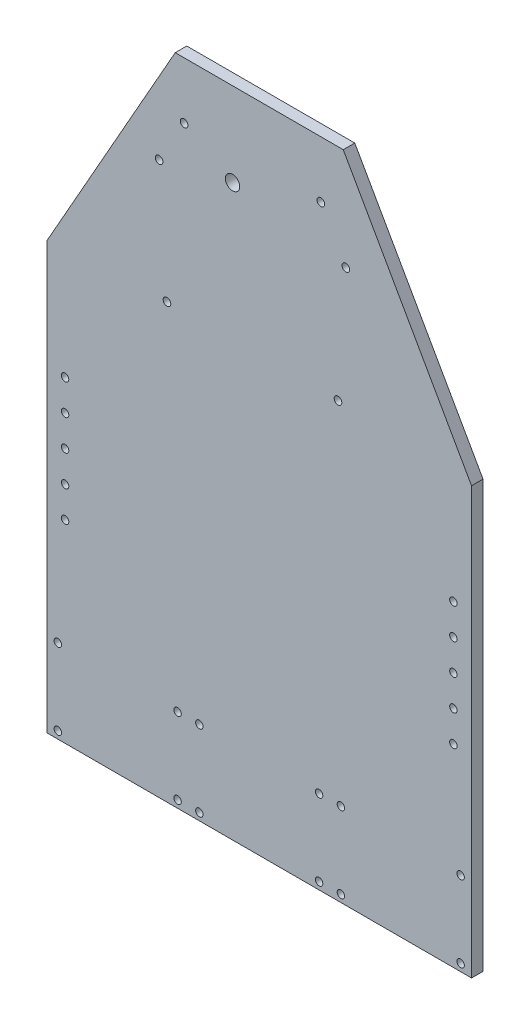
from build123d import *

# Parameters (mm, degrees)
SKETCH1_W           = 234
SKETCH1_H           = 360
BOSS_EXTRUDE1_DEPTH = 6.35
SKETCH2_R           = 2.05
SKETCH2_R_2         = 3.96875
SKETCH2_R_3         = 2.1
CUT_EXTRUDE1_DEPTH  = 10


with BuildPart() as part:
    # Sketch1 → Boss-Extrude1 (new body)
    with BuildSketch(Plane.XY):
        with Locations((3.724430118, 68.459164491)):
            Rectangle(SKETCH1_W, SKETCH1_H)
    extrude(amount=BOSS_EXTRUDE1_DEPTH)

    # Sketch2 → Cut-Extrude1 (cut)
    with BuildSketch(Plane(origin=(0, 0, 0), x_dir=(-1, 0, 0), z_dir=(0, 0, -1))):
        with Locations((107.275569882, -107.540835509)):
            Circle(SKETCH2_R)
        with Locations((107.275569882, -65.540835509)):
            Circle(SKETCH2_R)
        with Locations((41.275569882, -107.540835509)):
            Circle(SKETCH2_R)
        with Locations((41.275569882, -65.540835509)):
            Circle(SKETCH2_R)
        with Locations((29.275569882, -107.540835509)):
            Circle(SKETCH2_R)
        with Locations((29.275569882, -65.540835509)):
            Circle(SKETCH2_R)
        with Locations((-36.724430118, -107.540835509)):
            Circle(SKETCH2_R)
        with Locations((-36.724430118, -65.540835509)):
            Circle(SKETCH2_R)
        with Locations((-48.724430118, -107.540835509)):
            Circle(SKETCH2_R)
        with Locations((-48.724430118, -65.540835509)):
            Circle(SKETCH2_R)
        with Locations((-114.724430118, -107.540835509)):
            Circle(SKETCH2_R)
        with Locations((-114.724430118, -65.540835509)):
            Circle(SKETCH2_R)
        with Locations((10.98704263, 202.255343847)):
            Circle(SKETCH2_R_2)
        with Locations((-110.724430118, -4.879919884)):
            Circle(SKETCH2_R)
        with Locations((103.275569882, -4.879919884)):
            Circle(SKETCH2_R)
        with Locations((103.275569882, 12.120080116)):
            Circle(SKETCH2_R)
        with Locations((-110.724430118, 12.120080116)):
            Circle(SKETCH2_R)
        with Locations((103.275569882, 29.120080116)):
            Circle(SKETCH2_R)
        with Locations((-110.724430118, 29.120080116)):
            Circle(SKETCH2_R)
        with Locations((103.275569882, 46.120080116)):
            Circle(SKETCH2_R)
        with Locations((-110.724430118, 46.120080116)):
            Circle(SKETCH2_R)
        with Locations((103.275569882, 63.120080116)):
            Circle(SKETCH2_R)
        with Locations((-110.724430118, 63.120080116)):
            Circle(SKETCH2_R)
        with Locations((37.682916604, 217.255344198)):
            Circle(SKETCH2_R_3)
        with Locations((51.462268727, 192.880573325)):
            Circle(SKETCH2_R_3)
        with Locations((47.131206773, 127.255344198)):
            Circle(SKETCH2_R_3)
        with Locations((-37.682916604, 217.255344198)):
            Circle(SKETCH2_R_3)
        with Locations((-47.131206773, 127.255344198)):
            Circle(SKETCH2_R_3)
        with Locations((-51.462268727, 192.880573325)):
            Circle(SKETCH2_R_3)
        Polygon((-50.024430118, 248.459164491), (-120.724430118, 123.395497827), (-120.724430118, 248.459164491), align=None)
        Polygon((113.275569882, 248.459164491), (42.575569882, 248.459164491), (113.275569882, 123.395497827), align=None)
    extrude(amount=-CUT_EXTRUDE1_DEPTH, mode=Mode.SUBTRACT)


solid = part.part
